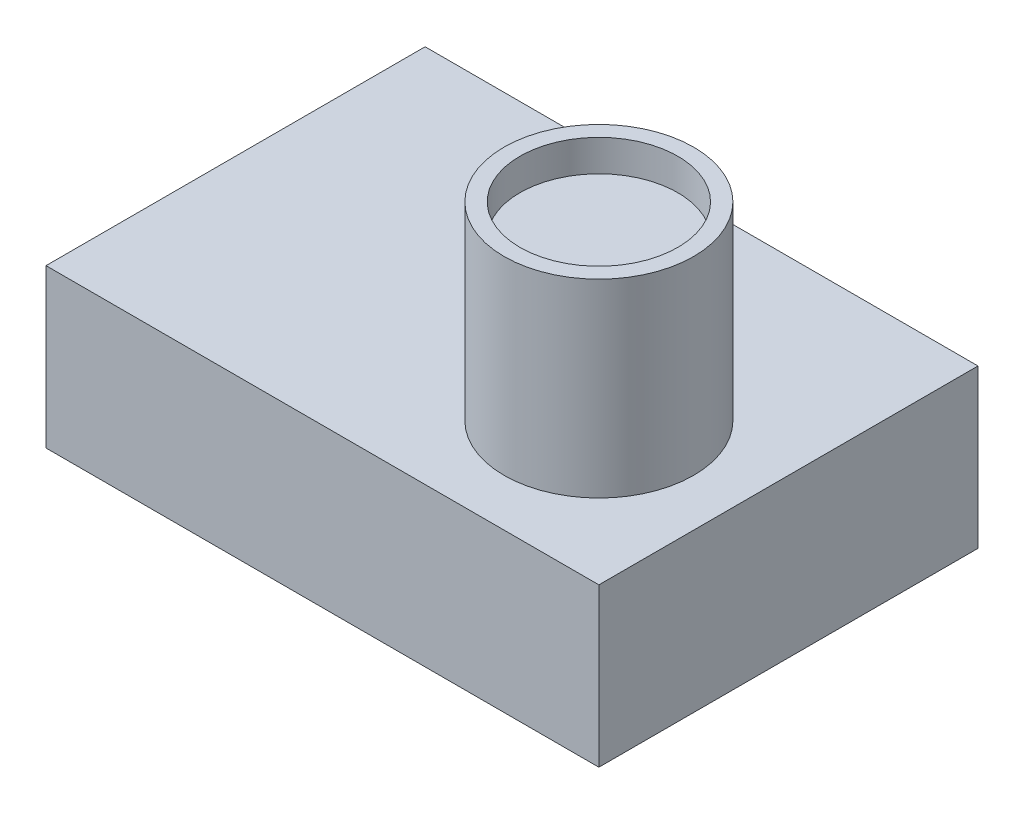
from build123d import *

# Parameters (mm, degrees)
SKETCH2_W           = 35
SKETCH2_H           = 24
BOSS_EXTRUDE1_DEPTH = 10
SKETCH3_R           = 6
BOSS_EXTRUDE2_DEPTH = 12
SKETCH4_R           = 5
CUT_EXTRUDE2_DEPTH  = 2


with BuildPart() as part:
    # Sketch2 → Boss-Extrude1 (new body)
    with BuildSketch(Plane(origin=(0, 0, 0), x_dir=(1, 0, 0), z_dir=(0, 1, 0))):
        Rectangle(SKETCH2_W, SKETCH2_H)
    extrude(amount=BOSS_EXTRUDE1_DEPTH)

    # Sketch3 → Boss-Extrude2 (add)
    with BuildSketch(Plane(origin=(0, 10, 0), x_dir=(1, 0, 0), z_dir=(0, 1, 0))):
        with Locations((8.5, -3)):
            Circle(SKETCH3_R)
    extrude(amount=BOSS_EXTRUDE2_DEPTH)

    # Sketch4 → Cut-Extrude2 (cut)
    with BuildSketch(Plane(origin=(0, 22, 0), x_dir=(1, 0, 0), z_dir=(0, 1, 0))):
        with Locations((8.5, -3)):
            Circle(SKETCH4_R)
    extrude(amount=-CUT_EXTRUDE2_DEPTH, mode=Mode.SUBTRACT)


solid = part.part
